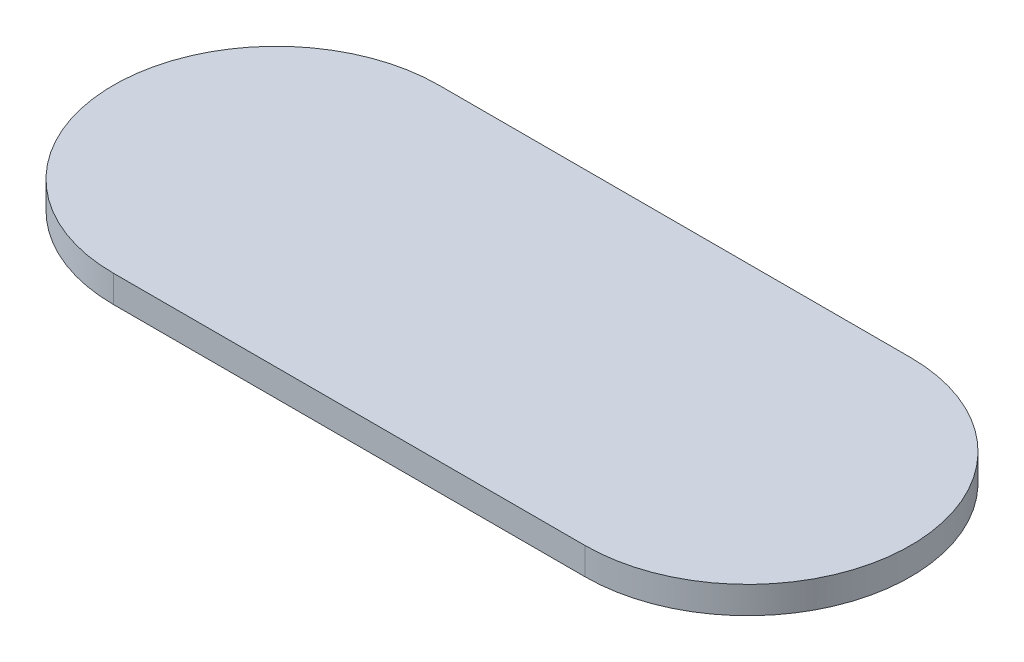
from build123d import *

# Parameters (mm, degrees)
BOSS_EXTRUDE2_DEPTH = 10


with BuildPart() as part:
    # Sketch2 → Boss-Extrude2 (new body)
    with BuildSketch(Plane(origin=(0, 0, 0), x_dir=(1, 0, 0), z_dir=(0, 1, 0))):
        with BuildLine():
            Line((-114.392523364, 60), (59.439252336, 60))
            ThreePointArc((59.439252336, 60), (119.439252336, 0), (59.439252336, -60))
            Line((59.439252336, -60), (-114.392523364, -60))
            ThreePointArc((-114.392523364, -60), (-174.392523364, 0), (-114.392523364, 60))
        make_face()
    extrude(amount=BOSS_EXTRUDE2_DEPTH)


solid = part.part
